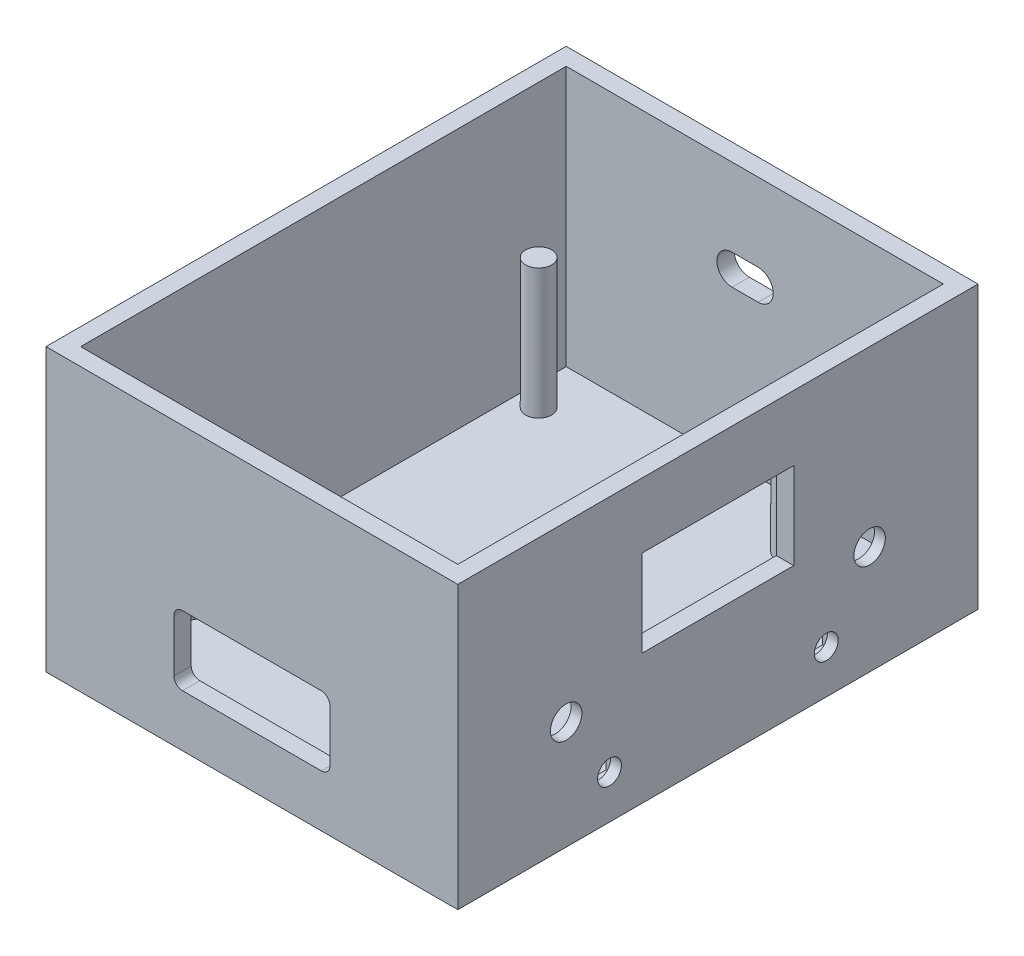
from build123d import *

# Parameters (mm, degrees)
SKETCH1_W                   = 95
SKETCH1_H                   = 120
BASE_DIMENSIONS_DEPTH       = 5
SKETCH2_W                   = 95
SKETCH2_H                   = 120
SKETCH2_W_2                 = 87
SKETCH2_H_2                 = 112
WALL_HEIGHT_AND_DEPTH_DEPTH = 60
SKETCH3_R                   = 3
SUPPORT_PEGS_DEPTH          = 30
SKETCH4_R                   = 3.625
SKETCH4_R_2                 = 2.75
SKETCH4_W                   = 35
SKETCH4_H                   = 20
FRONT_HOLES_DEPTH           = 4
SKETCH6_W                   = 13.6
SKETCH6_H                   = 13
SKETCH6_W_2                 = 6.3
SKETCH6_H_2                 = 6.3
EN_AND_B_INLAY_DEPTH        = 1.5
USB_SLOT_DEPTH              = 5
SKETCH10_W                  = 36
SKETCH10_H                  = 16
CUT_EXTRUDE1_DEPTH          = 10
FILLET1_R                   = 2


with BuildPart() as part:
    # Sketch1 → base dimensions (new body)
    with BuildSketch(Plane(origin=(0, 0, 0), x_dir=(1, 0, 0), z_dir=(0, 1, 0))):
        Rectangle(SKETCH1_W, SKETCH1_H)
    extrude(amount=BASE_DIMENSIONS_DEPTH)

    # Sketch2 → wall height and depth (add)
    with BuildSketch(Plane(origin=(0, 5, 0), x_dir=(1, 0, 0), z_dir=(0, 1, 0))):
        Rectangle(SKETCH2_W, SKETCH2_H)
        Rectangle(SKETCH2_W_2, SKETCH2_H_2, mode=Mode.SUBTRACT)
    extrude(amount=WALL_HEIGHT_AND_DEPTH_DEPTH)

    # Sketch3 → support pegs (add)
    with BuildSketch(Plane(origin=(0, 5, 0), x_dir=(1, 0, 0), z_dir=(0, 1, 0))):
        with Locations((-38.5, 44.645)):
            Circle(SKETCH3_R)
        with Locations((-38.5, -36)):
            Circle(SKETCH3_R)
        with Locations((32.62, -36)):
            Circle(SKETCH3_R)
        with Locations((19.285, 44.645)):
            Circle(SKETCH3_R)
    extrude(amount=SUPPORT_PEGS_DEPTH)

    # Sketch4 → front holes (cut)
    with BuildSketch(Plane(origin=(47.5, 0, 0), x_dir=(0, 0, -1), z_dir=(1, 0, 0))):
        with Locations((-35, 25)):
            Circle(SKETCH4_R)
        with Locations((-25, 10)):
            Circle(SKETCH4_R_2)
        with Locations((25, 10)):
            Circle(SKETCH4_R_2)
        with Locations((35, 25)):
            Circle(SKETCH4_R)
        with Locations((0, 40)):
            Rectangle(SKETCH4_W, SKETCH4_H)
    extrude(amount=-FRONT_HOLES_DEPTH, mode=Mode.SUBTRACT)

    # Sketch6 → en and b inlay (cut)
    with BuildSketch(Plane.ZY.offset(-43.5)):
        with Locations((-35, 25)):
            Rectangle(SKETCH6_W, SKETCH6_H)
        with Locations((-25, 10)):
            Rectangle(SKETCH6_W_2, SKETCH6_H_2)
        with Locations((25, 10)):
            Rectangle(SKETCH6_W_2, SKETCH6_H_2)
        with Locations((35, 25)):
            Rectangle(SKETCH6_W, SKETCH6_H)
    extrude(amount=-EN_AND_B_INLAY_DEPTH, mode=Mode.SUBTRACT)

    # Sketch9 → usb slot (cut, through all)
    with BuildSketch(Plane.XY.offset(-56)):
        with BuildLine():
            Line((-5.236035164, 47), (0.763964836, 47))
            ThreePointArc((0.763964836, 47), (4.263964836, 43.5), (0.763964836, 40))
            Line((0.763964836, 40), (-5.236035164, 40))
            ThreePointArc((-5.236035164, 40), (-8.736035164, 43.5), (-5.236035164, 47))
        make_face()
    extrude(amount=-USB_SLOT_DEPTH, mode=Mode.SUBTRACT)

    # Sketch10 → Cut-Extrude1 (cut)
    with BuildSketch(Plane(origin=(0, 0, 56), x_dir=(-1, 0, 0), z_dir=(0, 0, -1))):
        with Locations((0, 20)):
            Rectangle(SKETCH10_W, SKETCH10_H)
    extrude(amount=-CUT_EXTRUDE1_DEPTH, mode=Mode.SUBTRACT)

    # Fillet1
    fillet1_edges = [part.edges().sort_by_distance(p)[0] for p in [
        (-18, 28, 58),
        (-18, 12, 58),
        (18, 12, 58),
        (18, 28, 58),
    ]]
    fillet(fillet1_edges, radius=FILLET1_R)


solid = part.part
